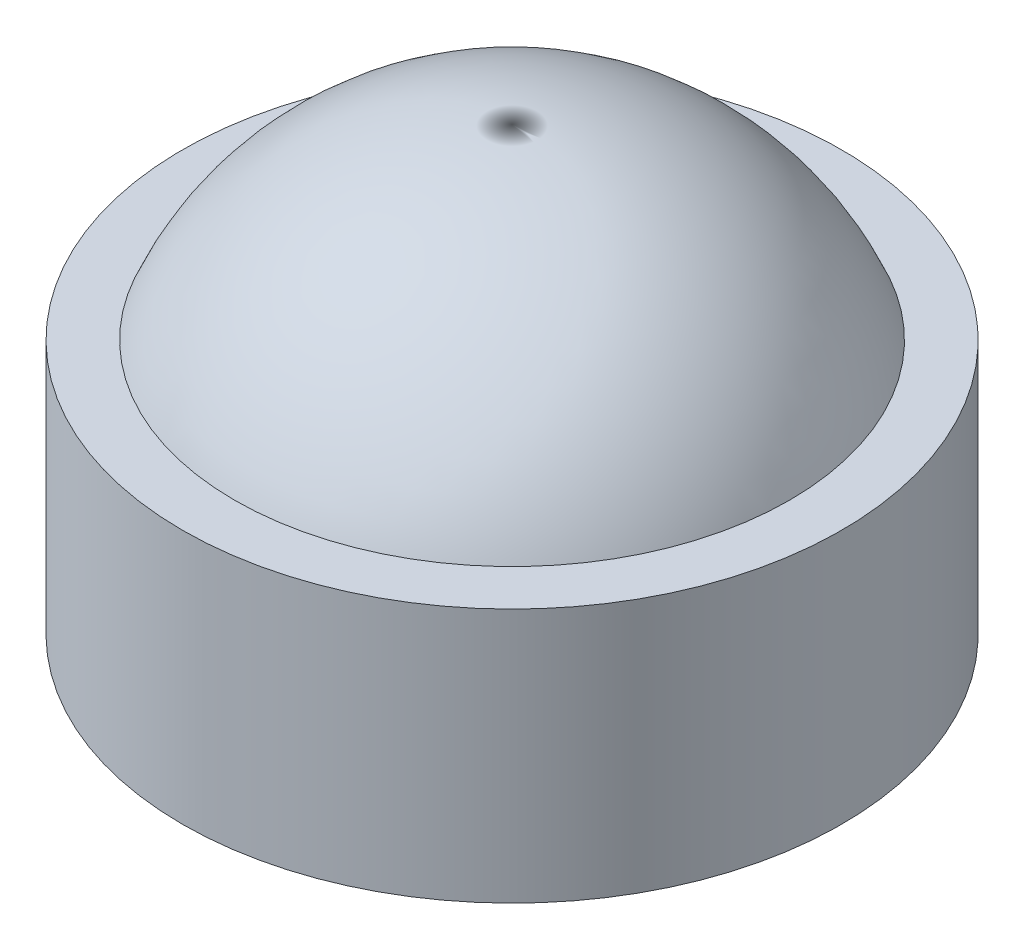
from build123d import *

# Parameters (mm, degrees)
SKETCH1_R           = 0.011
BOSS_EXTRUDE1_DEPTH = 0.0085


with BuildPart() as part:
    # Sketch1 → Boss-Extrude1 (new body)
    with BuildSketch(Plane(origin=(0, 0, 0), x_dir=(1, 0, 0), z_dir=(0, 1, 0))):
        Circle(SKETCH1_R)
    extrude(amount=BOSS_EXTRUDE1_DEPTH)

    # Sketch3 → Revolve3 (revolve)
    with BuildSketch(Plane.XY):
        with BuildLine():
            Line((0, 0.00473), (0, 0.01473))
            ThreePointArc((0, 0.01473), (-0.007071068, 0.011801068), (-0.01, 0.00473))
            Line((-0.01, 0.00473), (0, 0.00473))
        make_face()
    revolve(axis=Axis((0, 0.017427709, 0), (0, -1, 0)))


solid = part.part
